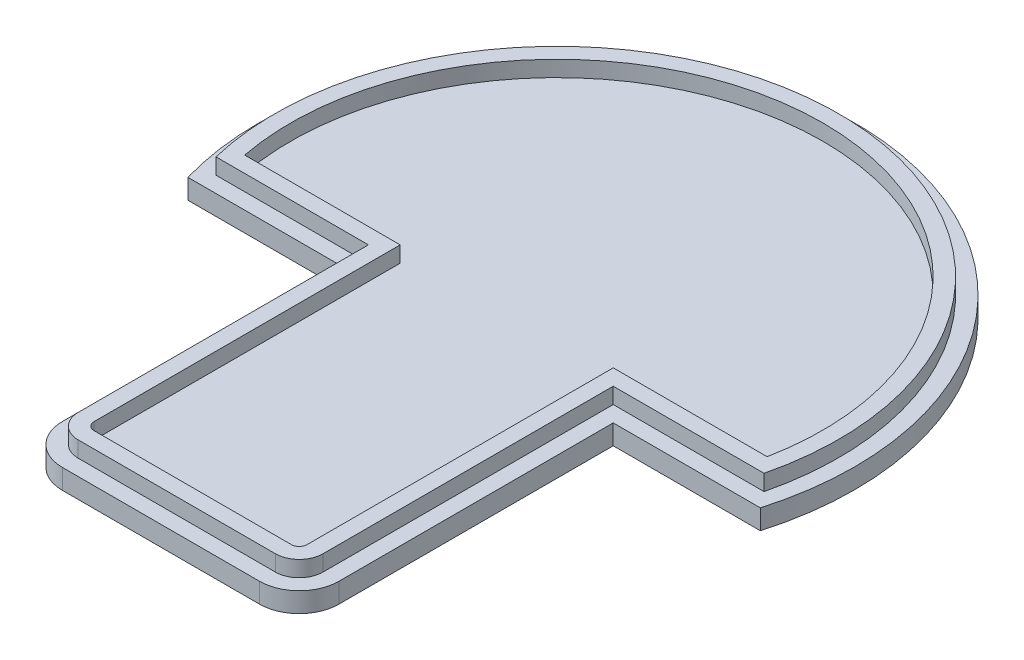
from build123d import *

# Parameters (mm, degrees)
SALIENTE_EXTRUIR1_DEPTH = 2.5
REDONDEO1_R             = 5
REDONDEO2_R             = 5
SALIENTE_EXTRUIR3_DEPTH = 2


with BuildPart() as part:
    # Croquis1 → Saliente-Extruir1 (new body)
    with BuildSketch(Plane(origin=(0, 0, 0), x_dir=(1, 0, 0), z_dir=(0, 1, 0))):
        with BuildLine():
            Line((-36.028689226, -10.401132279), (-17.309933046, -10.401132279))
            Line((-17.309933046, -10.401132279), (-17.309933046, -49.927805962))
            Line((-17.309933046, -49.927805962), (17.507919263, -49.927805962))
            Line((17.507919263, -49.927805962), (17.507919263, -10.401132279))
            Line((17.507919263, -10.401132279), (36.028689226, -10.401132279))
            ThreePointArc((36.028689226, -10.401132279), (0, 37.5), (-36.028689226, -10.401132279))
        make_face()
    extrude(amount=SALIENTE_EXTRUIR1_DEPTH)

    # Redondeo1
    redondeo1_edges = [part.edges().sort_by_distance(p)[0] for p in [
        (-17.309933046, 1.25, 49.927805962),
    ]]
    fillet(redondeo1_edges, radius=REDONDEO1_R)

    # Redondeo2
    redondeo2_edges = [part.edges().sort_by_distance(p)[0] for p in [
        (17.507919263, 1.25, 49.927805962),
    ]]
    fillet(redondeo2_edges, radius=REDONDEO2_R)

    # Croquis2 → Saliente-Extruir3 (add)
    with BuildSketch(Plane(origin=(0, 2.5, 0), x_dir=(1, 0, 0), z_dir=(0, 1, 0))):
        with BuildLine():
            ThreePointArc((-32.429476968, -8.401132279), (-32.671422926, -7.404601543), (-32.882753923, -6.401132279))
            Line((-32.882753923, -6.401132279), (-34.918125745, -6.401132279))
            ThreePointArc((-34.918125745, -6.401132279), (-34.719270751, -7.40420411), (-34.491607333, -8.401132279))
            Line((-34.491607333, -8.401132279), (-32.429476968, -8.401132279))
        make_face()
        with BuildLine():
            Line((17.507919263, -6.401132279), (13.507919263, -6.401132279))
            Line((13.507919263, -6.401132279), (13.507919263, -8.401132279))
            Line((13.507919263, -8.401132279), (13.507919263, -44.927805962))
            ThreePointArc((13.507919263, -44.927805962), (13.215026044, -45.634912744), (12.507919263, -45.927805962))
            Line((12.507919263, -45.927805962), (-12.309933046, -45.927805962))
            ThreePointArc((-12.309933046, -45.927805962), (-13.017039827, -45.634912744), (-13.309933046, -44.927805962))
            Line((-13.309933046, -44.927805962), (-13.309933046, -10.401132279))
            Line((-13.309933046, -10.401132279), (-13.309933046, -6.401132279))
            Line((-13.309933046, -6.401132279), (-17.309933046, -6.401132279))
            Line((-17.309933046, -6.401132279), (-32.882753923, -6.401132279))
            ThreePointArc((-32.882753923, -6.401132279), (-32.671422926, -7.404601543), (-32.429476968, -8.401132279))
            Line((-32.429476968, -8.401132279), (-17.309933046, -8.401132279))
            Line((-17.309933046, -8.401132279), (-15.309933046, -8.401132279))
            Line((-15.309933046, -8.401132279), (-15.309933046, -10.401132279))
            Line((-15.309933046, -10.401132279), (-15.309933046, -44.927805962))
            ThreePointArc((-15.309933046, -44.927805962), (-14.43125339, -47.049126306), (-12.309933046, -47.927805962))
            Line((-12.309933046, -47.927805962), (12.507919263, -47.927805962))
            ThreePointArc((12.507919263, -47.927805962), (14.629239607, -47.049126306), (15.507919263, -44.927805962))
            Line((15.507919263, -44.927805962), (15.507919263, -8.401132279))
            Line((15.507919263, -8.401132279), (17.507919263, -8.401132279))
            Line((17.507919263, -8.401132279), (32.429476968, -8.401132279))
            ThreePointArc((32.429476968, -8.401132279), (32.671422926, -7.404601543), (32.882753923, -6.401132279))
            Line((32.882753923, -6.401132279), (17.507919263, -6.401132279))
        make_face()
        with BuildLine():
            Line((34.918125745, -6.401132279), (32.882753923, -6.401132279))
            ThreePointArc((32.882753923, -6.401132279), (32.671422926, -7.404601543), (32.429476968, -8.401132279))
            Line((32.429476968, -8.401132279), (34.491607333, -8.401132279))
            ThreePointArc((34.491607333, -8.401132279), (34.719270751, -7.40420411), (34.918125745, -6.401132279))
        make_face()
        with BuildLine():
            ThreePointArc((-32.882753923, -6.401132279), (0, 33.5), (32.882753923, -6.401132279))
            Line((32.882753923, -6.401132279), (34.918125745, -6.401132279))
            ThreePointArc((34.918125745, -6.401132279), (0, 35.5), (-34.918125745, -6.401132279))
            Line((-34.918125745, -6.401132279), (-32.882753923, -6.401132279))
        make_face()
    extrude(amount=SALIENTE_EXTRUIR3_DEPTH)


solid = part.part
